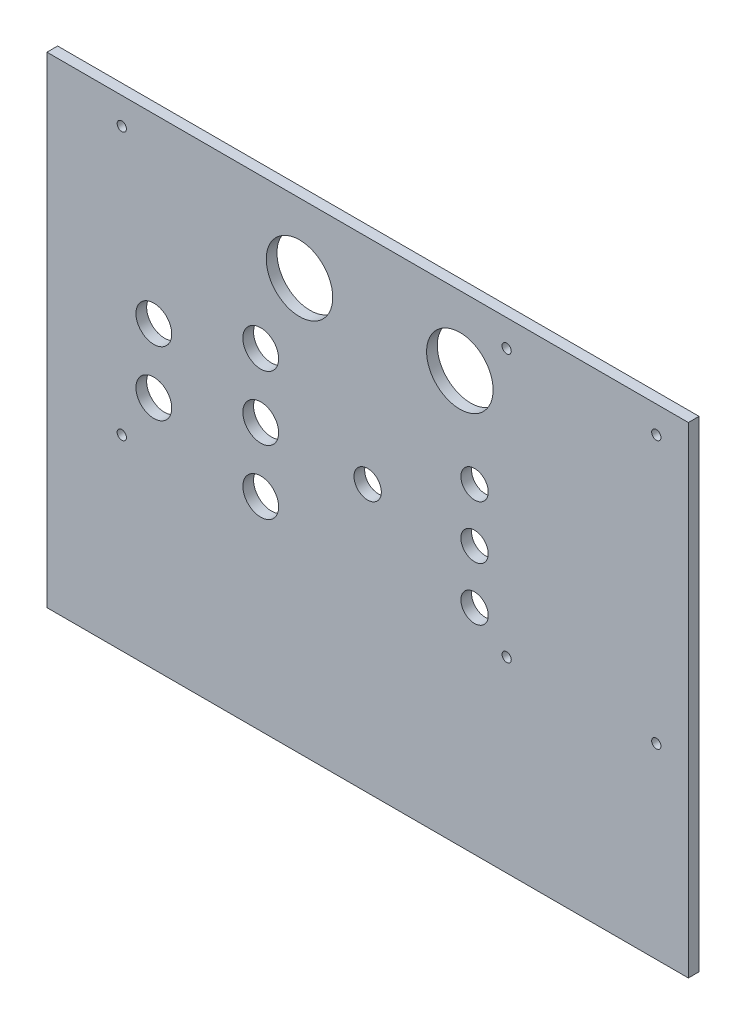
from build123d import *

# Parameters (mm, degrees)
SKETCH1_W           = 152.4
SKETCH1_H           = 114.3
SKETCH1_R           = 7.9
SKETCH1_R_2         = 7.899999948
SKETCH1_R_3         = 4.25
SKETCH1_R_4         = 3.25
SKETCH1_R_5         = 1.1
BOSS_EXTRUDE1_DEPTH = 2.54


with BuildPart() as part:
    # Sketch1 → Boss-Extrude1 (new body)
    with BuildSketch(Plane.XY):
        with Locations((76.2, 57.15)):
            Rectangle(SKETCH1_W, SKETCH1_H)
        with Locations((60.007194249, 97.79)):
            Circle(SKETCH1_R, mode=Mode.SUBTRACT)
        with Locations((98.107194249, 97.79)):
            Circle(SKETCH1_R_2, mode=Mode.SUBTRACT)
        with Locations((25.4, 71.12)):
            Circle(SKETCH1_R_3, mode=Mode.SUBTRACT)
        with Locations((50.8, 78.74)):
            Circle(SKETCH1_R_3, mode=Mode.SUBTRACT)
        with Locations((25.4, 55.88)):
            Circle(SKETCH1_R_3, mode=Mode.SUBTRACT)
        with Locations((101.6, 76.2)):
            Circle(SKETCH1_R_4, mode=Mode.SUBTRACT)
        with Locations((101.6, 63.5)):
            Circle(SKETCH1_R_4, mode=Mode.SUBTRACT)
        with Locations((101.6, 50.8)):
            Circle(SKETCH1_R_4, mode=Mode.SUBTRACT)
        with Locations((50.8, 63.5)):
            Circle(SKETCH1_R_3, mode=Mode.SUBTRACT)
        with Locations((50.8, 48.26)):
            Circle(SKETCH1_R_3, mode=Mode.SUBTRACT)
        with Locations((76.2, 63.5)):
            Circle(SKETCH1_R_4, mode=Mode.SUBTRACT)
        with Locations((17.78, 44.45)):
            Circle(SKETCH1_R_5, mode=Mode.SUBTRACT)
        with Locations((17.78, 107.95)):
            Circle(SKETCH1_R_5, mode=Mode.SUBTRACT)
        with Locations((109.22, 107.95)):
            Circle(SKETCH1_R_5, mode=Mode.SUBTRACT)
        with Locations((109.22, 44.45)):
            Circle(SKETCH1_R_5, mode=Mode.SUBTRACT)
        with Locations((144.78, 44.45)):
            Circle(SKETCH1_R_5, mode=Mode.SUBTRACT)
        with Locations((144.78, 107.95)):
            Circle(SKETCH1_R_5, mode=Mode.SUBTRACT)
    extrude(amount=BOSS_EXTRUDE1_DEPTH)


solid = part.part
